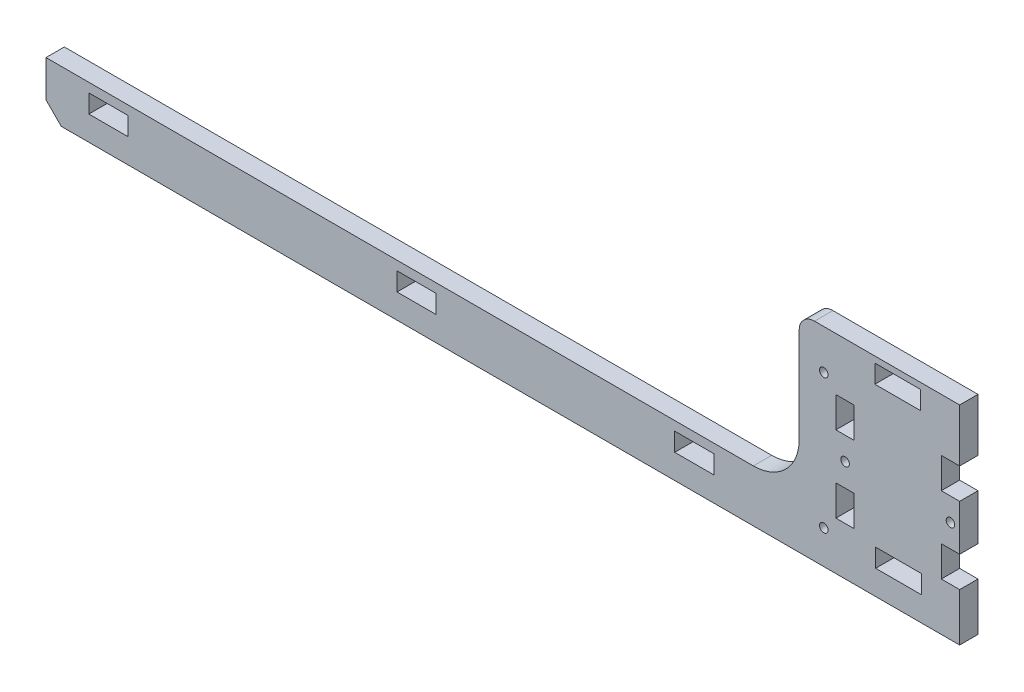
from build123d import *

# Parameters (mm, degrees)
SKETCH_1_R      = 1.4
SKETCH_1_W      = 12.8
SKETCH_1_H      = 6
SKETCH_1_W_2    = 15
SKETCH_1_W_3    = 6
SKETCH_1_H_2    = 10
EXTRUDE_1_DEPTH = 6


with BuildPart() as part:
    # Эскиз1 → Бобышка-Вытянуть1 (new body)
    with BuildSketch(Plane.XY):
        with BuildLine():
            Line((96.920798757, 2), (96.920798757, 25))
            Line((96.920798757, 25), (96.920798757, 33))
            ThreePointArc((96.920798757, 33), (98.385264851, 36.535533906), (101.920798757, 38))
            Line((101.920798757, 38), (149.389201243, 38))
            Line((149.389201243, 38), (149.389201243, 30))
            Line((149.389201243, 30), (149.389201243, 20.709265489))
            Line((149.389201243, 20.709265489), (143.389201243, 20.709265489))
            Line((143.389201243, 20.709265489), (143.389201243, 10.709265489))
            Line((143.389201243, 10.709265489), (149.389201243, 10.709265489))
            Line((149.389201243, 10.709265489), (149.389201243, -4.290734511))
            Line((149.389201243, -4.290734511), (143.389201243, -4.290734511))
            Line((143.389201243, -4.290734511), (143.389201243, -14.290734511))
            Line((143.389201243, -14.290734511), (149.389201243, -14.290734511))
            Line((149.389201243, -14.290734511), (149.389201243, -30))
            Line((149.389201243, -30), (-144.389201243, -30))
            Line((-144.389201243, -30), (-149.389201243, -25))
            Line((-149.389201243, -25), (-149.389201243, -13))
            Line((-149.389201243, -13), (81.920798757, -13))
            ThreePointArc((81.920798757, -13), (92.527400475, -8.606601718), (96.920798757, 2))
        make_face()
        with Locations((104.970798757, -19)):
            Circle(SKETCH_1_R, mode=Mode.SUBTRACT)
        with Locations((104.970798757, 25)):
            Circle(SKETCH_1_R, mode=Mode.SUBTRACT)
        with Locations((111.920798757, 3.209265489)):
            Circle(SKETCH_1_R, mode=Mode.SUBTRACT)
        with Locations((146.389201243, 3.209265489)):
            Circle(SKETCH_1_R, mode=Mode.SUBTRACT)
        with Locations((-128.98858016, -19)):
            Rectangle(SKETCH_1_W, SKETCH_1_H, mode=Mode.SUBTRACT)
        with Locations((-28.18858016, -19)):
            Rectangle(SKETCH_1_W, SKETCH_1_H, mode=Mode.SUBTRACT)
        with Locations((62.61141984, -19)):
            Rectangle(SKETCH_1_W, SKETCH_1_H, mode=Mode.SUBTRACT)
        with Locations((129.420798757, -19)):
            Rectangle(SKETCH_1_W_2, SKETCH_1_H, mode=Mode.SUBTRACT)
        with Locations((111.920798757, 15.709265489)):
            Rectangle(SKETCH_1_W_3, SKETCH_1_H_2, mode=Mode.SUBTRACT)
        with Locations((111.920798757, -9.290734511)):
            Rectangle(SKETCH_1_W_3, SKETCH_1_H_2, mode=Mode.SUBTRACT)
        with Locations((129.155798757, 33)):
            Rectangle(SKETCH_1_W_2, SKETCH_1_H, mode=Mode.SUBTRACT)
    extrude(amount=EXTRUDE_1_DEPTH)


solid = part.part
